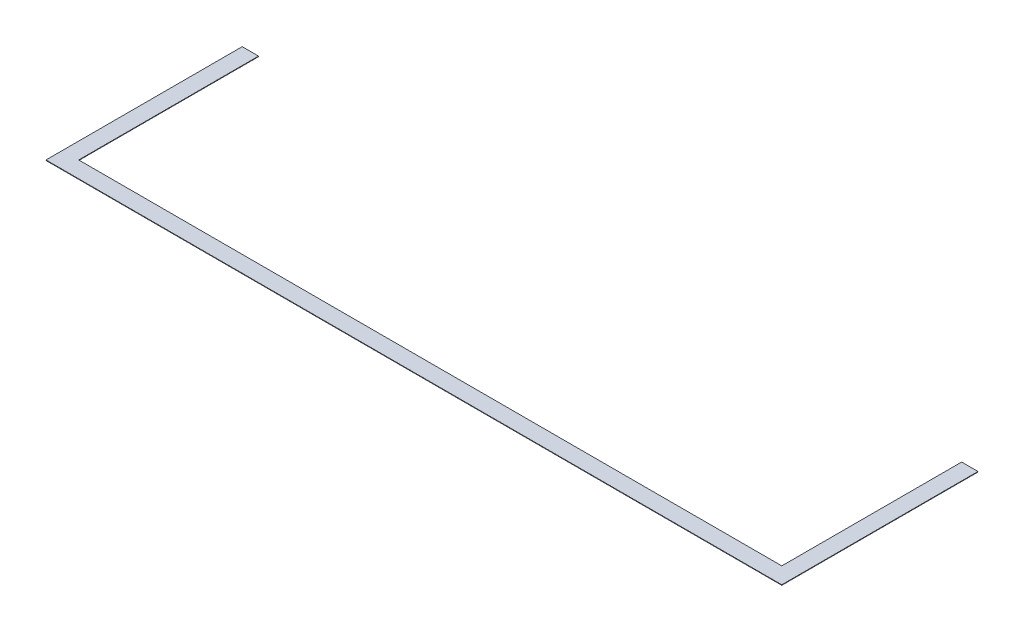
from build123d import *

# Parameters (mm, degrees)
BOSS_EXTRUDE1_DEPTH = 1.5875


with BuildPart() as part:
    # Sketch1 → Boss-Extrude1 (new body)
    with BuildSketch(Plane(origin=(0, 0, 0), x_dir=(1, 0, 0), z_dir=(0, 1, 0))):
        Polygon((0, 0), (0, -609.6), (2286, -609.6), (2286, 0), (2235.2, 0), (2235.2, -558.8), (50.8, -558.8), (50.8, 0), align=None)
    extrude(amount=BOSS_EXTRUDE1_DEPTH)


solid = part.part
